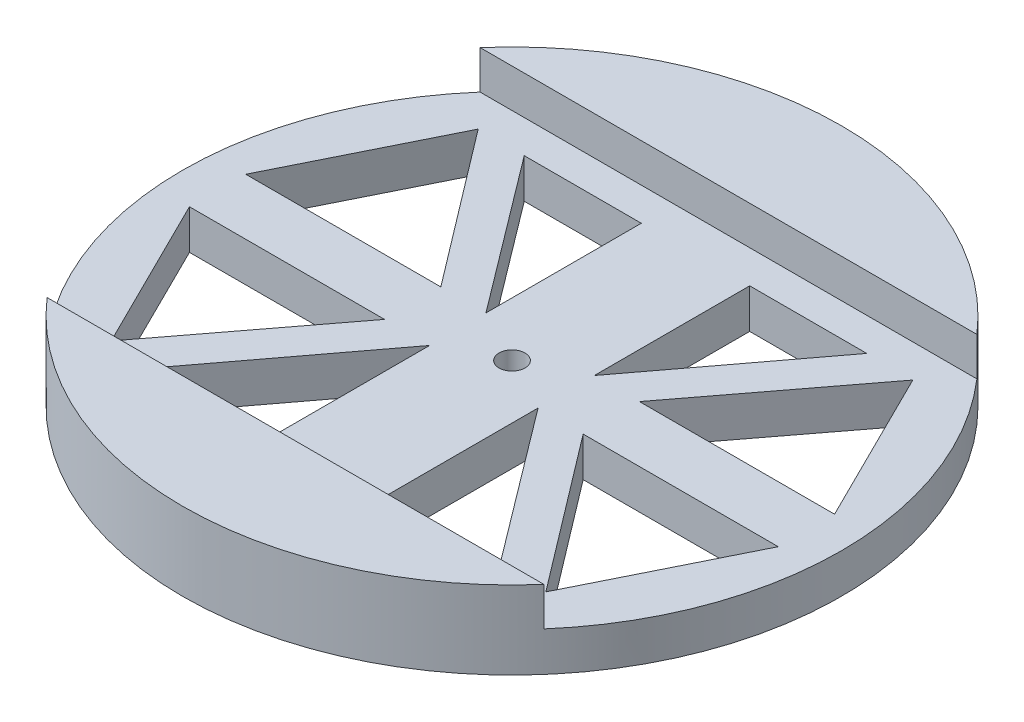
from build123d import *

# Parameters (mm, degrees)
SKETCH1_R           = 76
BOSS_EXTRUDE1_DEPTH = 18
CUT_EXTRUDE4_DEPTH  = 8.89
SKETCH5_R           = 3
CUT_EXTRUDE5_DEPTH  = 20
CUT_EXTRUDE6_DEPTH  = 10.11
CUT_EXTRUDE7_DEPTH  = 10.11


with BuildPart() as part:
    # Sketch1 → Boss-Extrude1 (new body)
    with BuildSketch(Plane(origin=(0, 0, 0), x_dir=(1, 0, 0), z_dir=(0, 1, 0))):
        Circle(SKETCH1_R)
    extrude(amount=BOSS_EXTRUDE1_DEPTH)

    # Sketch2 → Cut-Extrude4 (cut)
    with BuildSketch(Plane(origin=(0, 18, 0), x_dir=(1, 0, 0), z_dir=(0, 1, 0))):
        with BuildLine():
            Line((-58.007955522, 49.931796385), (58.007955522, 49.931796385))
            ThreePointArc((58.007955522, 49.931796385), (107.939751907, 0), (58.007955522, -49.931796385))
            Line((58.007955522, -49.931796385), (-58.007955522, -49.931796385))
            ThreePointArc((-58.007955522, -49.931796385), (-107.939751907, 0), (-58.007955522, 49.931796385))
        make_face()
    extrude(amount=-CUT_EXTRUDE4_DEPTH, mode=Mode.SUBTRACT)

    # Sketch5 → Cut-Extrude5 (cut)
    with BuildSketch(Plane(origin=(0, 9.11, 0), x_dir=(1, 0, 0), z_dir=(0, 1, 0))):
        Circle(SKETCH5_R)
    extrude(amount=-CUT_EXTRUDE5_DEPTH, mode=Mode.SUBTRACT)

    # Sketch7 → Cut-Extrude6 (cut, through all)
    with BuildSketch(Plane(origin=(0, 9.11, 0), x_dir=(1, 0, 0), z_dir=(0, 1, 0))):
        Polygon((-50.125135648, 42.322849323), (-67.902913426, 6.490592664), (-22.902913426, 6.490592664), align=None)
        Polygon((67.902913426, 6.490592664), (22.902913426, 6.490592664), (50.125135648, 42.322849323), align=None)
        Polygon((50.125135648, -42.322849323), (67.902913426, -6.490592664), (22.902913426, -6.490592664), align=None)
        Polygon((-67.902913426, -6.490592664), (-22.902913426, -6.490592664), (-50.125135648, -42.322849323), align=None)
    extrude(amount=-CUT_EXTRUDE6_DEPTH, mode=Mode.SUBTRACT)

    # Sketch9 → Cut-Extrude7 (cut, through all)
    with BuildSketch(Plane(origin=(0, 9.11, 0), x_dir=(1, 0, 0), z_dir=(0, 1, 0))):
        Polygon((-12.5, 6.490592664), (-12.5, 42.322849323), (-39.5, 42.322849323), align=None)
        Polygon((12.5, 6.490592664), (39.5, 42.322849323), (12.5, 42.322849323), align=None)
        Polygon((12.5, -6.490592664), (12.5, -42.322849323), (39.5, -42.322849323), align=None)
        Polygon((-12.5, -6.490592664), (-39.5, -42.322849323), (-12.5, -42.322849323), align=None)
    extrude(amount=-CUT_EXTRUDE7_DEPTH, mode=Mode.SUBTRACT)


solid = part.part
